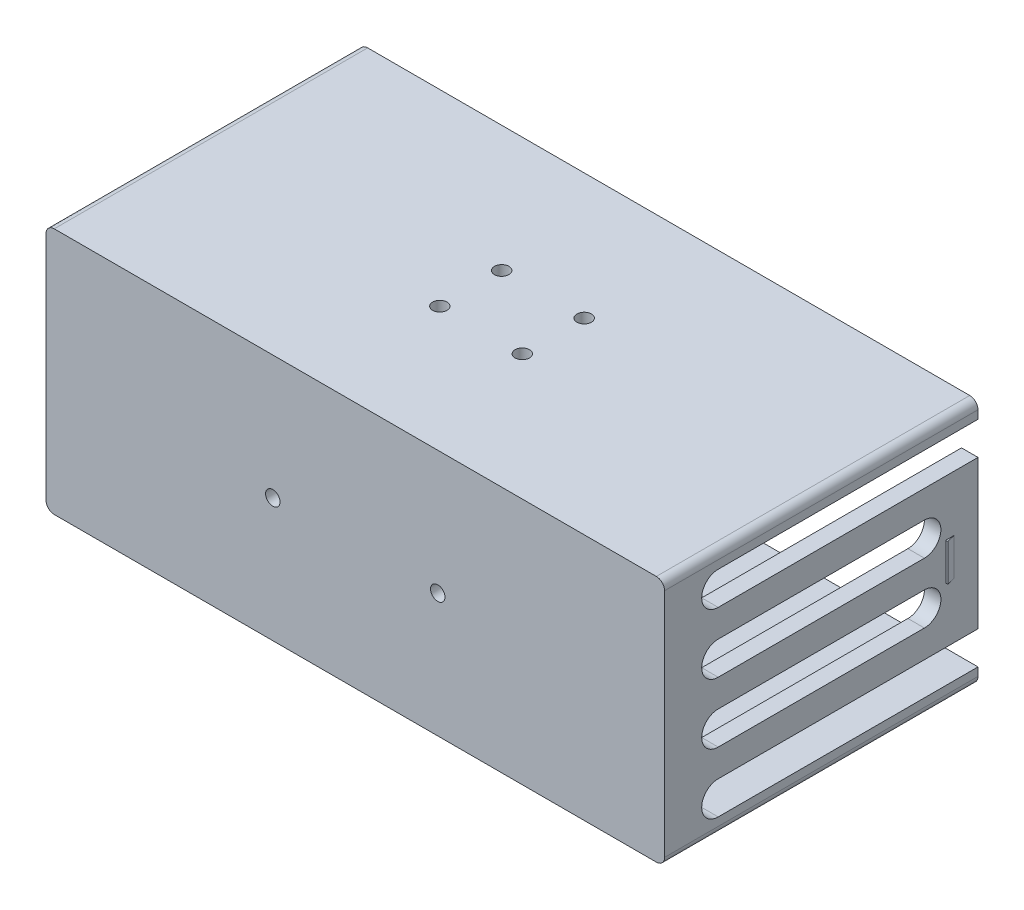
from build123d import *

# Parameters (mm, degrees)
SCHIZZO1_W                   = 150
SCHIZZO1_H                   = 60
ESTRUSIONE_ESTRUSIONE1_DEPTH = 38
SVUOTA1_T                    = -4
SCHIZZO2_R                   = 1.75
TAGLIO_ESTRUSIONE1_DEPTH     = 10
SCHIZZO4_R                   = 1.75
TAGLIO_ESTRUSIONE2_DEPTH     = 10
RIPETIZIONE_A_L1_COUNT       = 2
RIPETIZIONE_A_L1_PITCH       = 15
RIPETIZIONE_A_L1_COUNT_DIR2  = 2
RIPETIZIONE_A_L1_PITCH_DIR2  = 20
TAGLIO_ESTRUSIONE3_DEPTH     = 10
RIPETIZIONE_A_L2_COUNT       = 4
RIPETIZIONE_A_L2_PITCH       = 14.666666667
SCHIZZO6_W                   = 14.123548546
SCHIZZO6_H                   = 8
TAGLIO_ESTRUSIONE4_DEPTH     = 10
SPECCHIA2_COPY_1_SKETCH_W    = 14.123548546
SPECCHIA2_COPY_1_SKETCH_H    = 8
SPECCHIA2_COPY_1_DEPTH       = 10
SPECCHIA2_COPY_2_DEPTH       = 10
SPECCHIA2_COPY_3_DEPTH       = 10
SPECCHIA2_COPY_4_DEPTH       = 10
SPECCHIA2_COPY_5_DEPTH       = 10
ESTRUSIONE_ESTRUSIONE3_DEPTH = 4.5
RACCORDO3_R                  = 2


with BuildPart() as part:
    # Schizzo1 → Estrusione-Estrusione1 (new body, symmetric)
    with BuildSketch(Plane.XY):
        Rectangle(SCHIZZO1_W, SCHIZZO1_H)
    extrude(amount=ESTRUSIONE_ESTRUSIONE1_DEPTH, both=True)

    # Svuota1
    svuota1_openings = [part.faces().sort_by_distance(p)[0] for p in [
        (0, 0, -38),
    ]]
    offset(amount=SVUOTA1_T, openings=svuota1_openings, kind=Kind.INTERSECTION)

    # Schizzo2 → Taglio-Estrusione1 (cut)
    with BuildSketch(Plane(origin=(0, 0, 34), x_dir=(-1, 0, 0), z_dir=(0, 0, -1))):
        with Locations((20, 0)):
            Circle(SCHIZZO2_R)
    taglio_estrusione1 = extrude(amount=-TAGLIO_ESTRUSIONE1_DEPTH, mode=Mode.SUBTRACT)

    # Specchia1: Taglio-Estrusione1 across plane
    add(taglio_estrusione1.mirror(Plane(origin=(0, 0, 0), x_dir=(0, 0, 1), z_dir=(1, 0, 0))), mode=Mode.SUBTRACT)

    # Schizzo4 → Taglio-Estrusione2 (cut)
    with BuildSketch(Plane(origin=(0, 30, 0), x_dir=(1, 0, 0), z_dir=(0, 1, 0))):
        with Locations((10, 7.5)):
            Circle(SCHIZZO4_R)
    taglio_estrusione2 = extrude(amount=-TAGLIO_ESTRUSIONE2_DEPTH, mode=Mode.SUBTRACT)

    # Ripetizione a L1: Taglio-Estrusione2 2 × 2
    with Locations(*[(-j * RIPETIZIONE_A_L1_PITCH_DIR2, 0, i * RIPETIZIONE_A_L1_PITCH) for i in range(RIPETIZIONE_A_L1_COUNT) for j in range(RIPETIZIONE_A_L1_COUNT_DIR2) if (i, j) != (0, 0)]):
        add(taglio_estrusione2, mode=Mode.SUBTRACT)

    # Schizzo5 → Taglio-Estrusione3 (cut)
    with BuildSketch(Plane.ZY.offset(75)):
        with BuildLine():
            Line((-25, 26), (25, 26))
            ThreePointArc((25, 26), (29, 22), (25, 18))
            Line((25, 18), (-25, 18))
            ThreePointArc((-25, 18), (-29, 22), (-25, 26))
        make_face()
    taglio_estrusione3 = extrude(amount=-TAGLIO_ESTRUSIONE3_DEPTH, mode=Mode.SUBTRACT)

    # Ripetizione a L2: Taglio-Estrusione3 ×4
    with Locations(*[(0, -i * RIPETIZIONE_A_L2_PITCH, 0) for i in range(1, RIPETIZIONE_A_L2_COUNT)]):
        add(taglio_estrusione3, mode=Mode.SUBTRACT)

    # Schizzo6 → Taglio-Estrusione4 (cut)
    with BuildSketch(Plane.ZY.offset(75)):
        with Locations((-30.938225727, -22)):
            Rectangle(SCHIZZO6_W, SCHIZZO6_H)
    taglio_estrusione4 = extrude(amount=-TAGLIO_ESTRUSIONE4_DEPTH, mode=Mode.SUBTRACT)

    # Specchia3: Taglio-Estrusione4 across plane
    add(taglio_estrusione4.mirror(Plane.ZX), mode=Mode.SUBTRACT)

    # Specchia2: Taglio-Estrusione4 across plane
    add(taglio_estrusione4.mirror(Plane(origin=(0, 0, 0), x_dir=(0, 0, 1), z_dir=(1, 0, 0))), mode=Mode.SUBTRACT)

    # Specchia2 copy 1 sketch → Specchia2 copy 1 (cut)
    with BuildSketch(Plane(origin=(75, 0, 0), x_dir=(0, 0, 1), z_dir=(1, 0, 0))):
        with Locations((-30.938225727, -22)):
            Rectangle(SPECCHIA2_COPY_1_SKETCH_W, SPECCHIA2_COPY_1_SKETCH_H)
    extrude(amount=-SPECCHIA2_COPY_1_DEPTH, mode=Mode.SUBTRACT)

    # Specchia2 copy 2 sketch → Specchia2 copy 2 (cut)
    with BuildSketch(Plane(origin=(75, -14.666666667, 0), x_dir=(0, 0, 1), z_dir=(1, 0, 0))):
        with BuildLine():
            Line((-25, -26), (25, -26))
            ThreePointArc((25, -26), (29, -22), (25, -18))
            Line((25, -18), (-25, -18))
            ThreePointArc((-25, -18), (-29, -22), (-25, -26))
        make_face()
    extrude(amount=-SPECCHIA2_COPY_2_DEPTH, mode=Mode.SUBTRACT)

    # Specchia2 copy 3 sketch → Specchia2 copy 3 (cut)
    with BuildSketch(Plane(origin=(75, -29.333333333, 0), x_dir=(0, 0, 1), z_dir=(1, 0, 0))):
        with BuildLine():
            Line((-25, -26), (25, -26))
            ThreePointArc((25, -26), (29, -22), (25, -18))
            Line((25, -18), (-25, -18))
            ThreePointArc((-25, -18), (-29, -22), (-25, -26))
        make_face()
    extrude(amount=-SPECCHIA2_COPY_3_DEPTH, mode=Mode.SUBTRACT)

    # Specchia2 copy 4 sketch → Specchia2 copy 4 (cut)
    with BuildSketch(Plane(origin=(75, -44, 0), x_dir=(0, 0, 1), z_dir=(1, 0, 0))):
        with BuildLine():
            Line((-25, -26), (25, -26))
            ThreePointArc((25, -26), (29, -22), (25, -18))
            Line((25, -18), (-25, -18))
            ThreePointArc((-25, -18), (-29, -22), (-25, -26))
        make_face()
    extrude(amount=-SPECCHIA2_COPY_4_DEPTH, mode=Mode.SUBTRACT)

    # Specchia2 copy 5 sketch → Specchia2 copy 5 (cut)
    with BuildSketch(Plane(origin=(75, 0, 0), x_dir=(0, 0, 1), z_dir=(1, 0, 0))):
        with BuildLine():
            Line((-25, -26), (25, -26))
            ThreePointArc((25, -26), (29, -22), (25, -18))
            Line((25, -18), (-25, -18))
            ThreePointArc((-25, -18), (-29, -22), (-25, -26))
        make_face()
    extrude(amount=-SPECCHIA2_COPY_5_DEPTH, mode=Mode.SUBTRACT)

    # Schizzo9 → Estrusione-Estrusione3 (add, symmetric)
    with BuildSketch(Plane(origin=(0, 0, 0), x_dir=(1, 0, 0), z_dir=(0, 1, 0))):
        Polygon((-75, 30.2), (-75.5, 30.2), (-75, 32.2), align=None)
    estrusione_estrusione3 = extrude(amount=ESTRUSIONE_ESTRUSIONE3_DEPTH, both=True)

    # Specchia11: Estrusione-Estrusione3 across plane
    add(estrusione_estrusione3.mirror(Plane(origin=(0, 0, 0), x_dir=(0, 0, 1), z_dir=(1, 0, 0))))

    # Raccordo3
    raccordo3_edges = [part.edges().sort_by_distance(p)[0] for p in [
        (75, -30, 0),
        (-75, -30, 0),
        (-75, 30, 0),
        (75, 30, 0),
    ]]
    fillet(raccordo3_edges, radius=RACCORDO3_R)


solid = part.part
